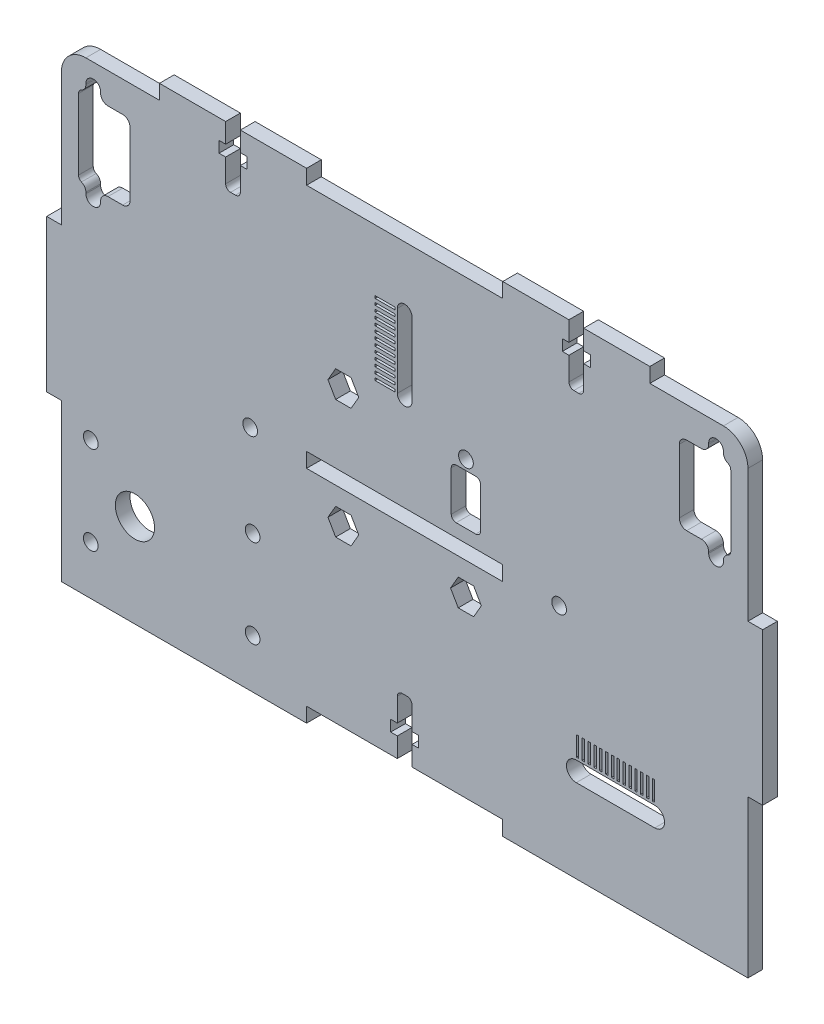
from build123d import *

# Parameters (mm, degrees)
ESBO_O1_W                   = 140
ESBO_O1_H                   = 95
RESSALTO_EXTRUS_O1_DEPTH    = 1.5
ESBO_O2_R                   = 1.5
ESBO_O2_W                   = 40
ESBO_O2_H                   = 3
CORTE_EXTRUS_O1_DEPTH       = 4
ESBO_O3_W                   = 3
ESBO_O3_H                   = 31
ESBO_O3_W_2                 = 30
ESBO_O3_H_2                 = 3
RESSALTO_EXTRUS_O2_DEPTH    = 3
ESBO_O30_R                  = 4
CORTE_EXTRUS_O11_DEPTH      = 1
CORTE_EXTRUS_O11_DEPTH_BACK = 4
ESBO_O31_R                  = 1.5
CORTE_EXTRUS_O12_DEPTH      = 1
CORTE_EXTRUS_O12_DEPTH_BACK = 4
ESBO_O4_W                   = 0.5
ESBO_O4_H                   = 4
CORTE_EXTRUS_O2_DEPTH       = 4
CUT_EXTRUDE2_DEPTH          = 2.5
CUT_EXTRUDE2_DEPTH_BACK     = 2.5
CUT_EXTRUDE6_DEPTH          = 1
CUT_EXTRUDE6_DEPTH_BACK     = 4
CUT_EXTRUDE8_DEPTH          = 2.5
CUT_EXTRUDE8_DEPTH_BACK     = 2.5
SKETCH12_W                  = 4
SKETCH12_H                  = 0.5
CUT_EXTRUDE9_DEPTH          = 4
SKETCH16_R                  = 1.5
CUT_EXTRUDE12_DEPTH         = 2.5
CUT_EXTRUDE12_DEPTH_BACK    = 2.5
FILLET1_R                   = 5


with BuildPart() as part:
    # Esboço1 → Ressalto-extrusão1 (new body, symmetric)
    with BuildSketch(Plane.XY):
        Rectangle(ESBO_O1_W, ESBO_O1_H)
    extrude(amount=RESSALTO_EXTRUS_O1_DEPTH, both=True)

    # Esboço2 → Corte-extrusão1 (cut, through all)
    with BuildSketch(Plane.XY.offset(1.5)):
        with Locations((-31.5, -1)):
            Circle(ESBO_O2_R)
        with Locations((31.5, -1)):
            Circle(ESBO_O2_R)
        with Locations((0, -46)):
            Rectangle(ESBO_O2_W, ESBO_O2_H)
        with Locations((0, -1)):
            Rectangle(ESBO_O2_W, ESBO_O2_H)
    extrude(amount=-CORTE_EXTRUS_O1_DEPTH, mode=Mode.SUBTRACT)

    # Esboço3 → Ressalto-extrusão2 (add, through all)
    with BuildSketch(Plane.XY.offset(1.5)):
        with Locations((71.5, 0)):
            Rectangle(ESBO_O3_W, ESBO_O3_H)
        with Locations((-71.5, 0)):
            Rectangle(ESBO_O3_W, ESBO_O3_H)
        with Locations((-35, 49)):
            Rectangle(ESBO_O3_W_2, ESBO_O3_H_2)
        with Locations((35, 49)):
            Rectangle(ESBO_O3_W_2, ESBO_O3_H_2)
    extrude(amount=-RESSALTO_EXTRUS_O2_DEPTH)

    # Esboço30 → Corte-extrusão11 (cut, two sides)
    with BuildSketch(Plane(origin=(0, 0, -1.5), x_dir=(-1, 0, 0), z_dir=(0, 0, -1))) as corte_extrus_o11_sk:
        with Locations((55, -28.5)):
            Circle(ESBO_O30_R)
    extrude(amount=CORTE_EXTRUS_O11_DEPTH, mode=Mode.SUBTRACT)
    extrude(corte_extrus_o11_sk.sketch, amount=-CORTE_EXTRUS_O11_DEPTH_BACK, mode=Mode.SUBTRACT)

    # Esboço31 → Corte-extrusão12 (cut, two sides)
    with BuildSketch(Plane(origin=(0, 0, -1.5), x_dir=(-1, 0, 0), z_dir=(0, 0, -1))) as corte_extrus_o12_sk:
        with Locations((64, -19.5)):
            Circle(ESBO_O31_R)
        with Locations((64, -37.5)):
            Circle(ESBO_O31_R)
        with Locations((31, -19.5)):
            Circle(ESBO_O31_R)
        with Locations((31, -37.5)):
            Circle(ESBO_O31_R)
    extrude(amount=CORTE_EXTRUS_O12_DEPTH, mode=Mode.SUBTRACT)
    extrude(corte_extrus_o12_sk.sketch, amount=-CORTE_EXTRUS_O12_DEPTH_BACK, mode=Mode.SUBTRACT)

    # Esboço4 → Corte-extrusão2 (cut, through all)
    with BuildSketch(Plane.XY.offset(1.5)):
        with BuildLine():
            Line((35, -26.5), (51, -26.5))
            ThreePointArc((51, -26.5), (53, -28.5), (51, -30.5))
            Line((51, -30.5), (35, -30.5))
            ThreePointArc((35, -30.5), (33, -28.5), (35, -26.5))
        make_face()
        with Locations((35.25, -24)):
            Rectangle(ESBO_O4_W, ESBO_O4_H)
        with Locations((36.442307692, -24)):
            Rectangle(ESBO_O4_W, ESBO_O4_H)
        with Locations((37.634615385, -24)):
            Rectangle(ESBO_O4_W, ESBO_O4_H)
        with Locations((38.826923077, -24)):
            Rectangle(ESBO_O4_W, ESBO_O4_H)
        with Locations((40.019230769, -24)):
            Rectangle(ESBO_O4_W, ESBO_O4_H)
        with Locations((41.211538462, -24)):
            Rectangle(ESBO_O4_W, ESBO_O4_H)
        with Locations((42.403846154, -24)):
            Rectangle(ESBO_O4_W, ESBO_O4_H)
        with Locations((43.596153846, -24)):
            Rectangle(ESBO_O4_W, ESBO_O4_H)
        with Locations((44.788461538, -24)):
            Rectangle(ESBO_O4_W, ESBO_O4_H)
        with Locations((45.980769231, -24)):
            Rectangle(ESBO_O4_W, ESBO_O4_H)
        with Locations((47.173076923, -24)):
            Rectangle(ESBO_O4_W, ESBO_O4_H)
        with Locations((48.365384615, -24)):
            Rectangle(ESBO_O4_W, ESBO_O4_H)
        with Locations((49.557692308, -24)):
            Rectangle(ESBO_O4_W, ESBO_O4_H)
        with Locations((50.75, -24)):
            Rectangle(ESBO_O4_W, ESBO_O4_H)
    extrude(amount=-CORTE_EXTRUS_O2_DEPTH, mode=Mode.SUBTRACT)

    # Sketch5 → Cut-Extrude2 (cut, two sides)
    with BuildSketch(Plane.XY) as cut_extrude2_sk:
        with BuildLine():
            Line((-1.5, -44.5), (1.5, -44.5))
            Line((1.5, -44.5), (1.5, -40.5))
            Line((1.5, -40.5), (2.85, -40.5))
            Line((2.85, -40.5), (2.85, -38.23))
            Line((2.85, -38.23), (1.5, -38.23))
            Line((1.5, -38.23), (1.5, -33.5))
            ThreePointArc((1.5, -33.5), (1.207106781, -32.792893219), (0.5, -32.5))
            Line((0.5, -32.5), (-0.5, -32.5))
            ThreePointArc((-0.5, -32.5), (-1.207106781, -32.792893219), (-1.5, -33.5))
            Line((-1.5, -33.5), (-1.5, -38.23))
            Line((-1.5, -38.23), (-2.85, -38.23))
            Line((-2.85, -38.23), (-2.85, -40.5))
            Line((-2.85, -40.5), (-1.5, -40.5))
            Line((-1.5, -40.5), (-1.5, -44.5))
        make_face()
    extrude(amount=CUT_EXTRUDE2_DEPTH, mode=Mode.SUBTRACT)
    extrude(cut_extrude2_sk.sketch, amount=-CUT_EXTRUDE2_DEPTH_BACK, mode=Mode.SUBTRACT)

    # Sketch8 → Cut-Extrude6 (cut, two sides)
    with BuildSketch(Plane.XY.offset(1.5)) as cut_extrude6_sk:
        with BuildLine():
            Line((-56, 39.75), (-56, 26.75))
            ThreePointArc((-56, 26.75), (-56.439339828, 25.689339828), (-57.5, 25.25))
            Line((-57.5, 25.25), (-60.5, 25.25))
            ThreePointArc((-60.5, 25.25), (-61.560660172, 24.810660172), (-62, 23.75))
            Line((-62, 23.75), (-62, 23.5))
            ThreePointArc((-62, 23.5), (-63.5, 22), (-65, 23.5))
            Line((-65, 23.5), (-65, 23.75))
            ThreePointArc((-65, 23.75), (-65.24500996, 24.571583836), (-65.9, 25.124772708))
            ThreePointArc((-65.9, 25.124772708), (-66.336660027, 25.49356529), (-66.5, 26.041287847))
            Line((-66.5, 26.041287847), (-66.5, 40.458712153))
            ThreePointArc((-66.5, 40.458712153), (-66.336660027, 41.00643471), (-65.9, 41.375227292))
            ThreePointArc((-65.9, 41.375227292), (-65.24500996, 41.928416164), (-65, 42.75))
            Line((-65, 42.75), (-65, 43))
            ThreePointArc((-65, 43), (-63.5, 44.5), (-62, 43))
            Line((-62, 43), (-62, 42.75))
            ThreePointArc((-62, 42.75), (-61.560660172, 41.689339828), (-60.5, 41.25))
            Line((-60.5, 41.25), (-57.5, 41.25))
            ThreePointArc((-57.5, 41.25), (-56.439339828, 40.810660172), (-56, 39.75))
        make_face()
        with BuildLine():
            Line((56, 39.75), (56, 26.75))
            ThreePointArc((56, 26.75), (56.439339828, 25.689339828), (57.5, 25.25))
            Line((57.5, 25.25), (60.5, 25.25))
            ThreePointArc((60.5, 25.25), (61.560660172, 24.810660172), (62, 23.75))
            Line((62, 23.75), (62, 23.5))
            ThreePointArc((62, 23.5), (63.5, 22), (65, 23.5))
            Line((65, 23.5), (65, 23.75))
            ThreePointArc((65, 23.75), (65.24500996, 24.571583836), (65.9, 25.124772708))
            ThreePointArc((65.9, 25.124772708), (66.336660027, 25.49356529), (66.5, 26.041287847))
            Line((66.5, 26.041287847), (66.5, 40.458712153))
            ThreePointArc((66.5, 40.458712153), (66.336660027, 41.00643471), (65.9, 41.375227292))
            ThreePointArc((65.9, 41.375227292), (65.24500996, 41.928416164), (65, 42.75))
            Line((65, 42.75), (65, 43))
            ThreePointArc((65, 43), (63.5, 44.5), (62, 43))
            Line((62, 43), (62, 42.75))
            ThreePointArc((62, 42.75), (61.560660172, 41.689339828), (60.5, 41.25))
            Line((60.5, 41.25), (57.5, 41.25))
            ThreePointArc((57.5, 41.25), (56.439339828, 40.810660172), (56, 39.75))
        make_face()
    extrude(amount=CUT_EXTRUDE6_DEPTH, mode=Mode.SUBTRACT)
    extrude(cut_extrude6_sk.sketch, amount=-CUT_EXTRUDE6_DEPTH_BACK, mode=Mode.SUBTRACT)

    # Sketch11 → Cut-Extrude8 (cut, two sides)
    with BuildSketch(Plane.XY) as cut_extrude8_sk:
        with BuildLine():
            Line((-36.5, 50.5), (-33.5, 50.5))
            Line((-33.5, 50.5), (-33.5, 46.5))
            Line((-33.5, 46.5), (-32.15, 46.5))
            Line((-32.15, 46.5), (-32.15, 44.23))
            Line((-32.15, 44.23), (-33.5, 44.23))
            Line((-33.5, 44.23), (-33.5, 39.5))
            ThreePointArc((-33.5, 39.5), (-33.792893219, 38.792893219), (-34.5, 38.5))
            Line((-34.5, 38.5), (-35.5, 38.5))
            ThreePointArc((-35.5, 38.5), (-36.207106781, 38.792893219), (-36.5, 39.5))
            Line((-36.5, 39.5), (-36.5, 44.23))
            Line((-36.5, 44.23), (-37.85, 44.23))
            Line((-37.85, 44.23), (-37.85, 46.5))
            Line((-37.85, 46.5), (-36.5, 46.5))
            Line((-36.5, 46.5), (-36.5, 50.5))
        make_face()
        with BuildLine():
            Line((33.5, 44.23), (32.15, 44.23))
            Line((32.15, 44.23), (32.15, 46.5))
            Line((32.15, 46.5), (33.5, 46.5))
            Line((33.5, 46.5), (33.5, 50.5))
            Line((33.5, 50.5), (36.5, 50.5))
            Line((36.5, 50.5), (36.5, 46.5))
            Line((36.5, 46.5), (37.85, 46.5))
            Line((37.85, 46.5), (37.85, 44.23))
            Line((37.85, 44.23), (36.5, 44.23))
            Line((36.5, 44.23), (36.5, 39.5))
            ThreePointArc((36.5, 39.5), (36.207106781, 38.792893219), (35.5, 38.5))
            Line((35.5, 38.5), (34.5, 38.5))
            ThreePointArc((34.5, 38.5), (33.792893219, 38.792893219), (33.5, 39.5))
            Line((33.5, 39.5), (33.5, 44.23))
        make_face()
    extrude(amount=CUT_EXTRUDE8_DEPTH, mode=Mode.SUBTRACT)
    extrude(cut_extrude8_sk.sketch, amount=-CUT_EXTRUDE8_DEPTH_BACK, mode=Mode.SUBTRACT)

    # Sketch12 → Cut-Extrude9 (cut, through all)
    with BuildSketch(Plane.XY.offset(1.5)):
        with Locations((-4, 21.458333333)):
            Rectangle(SKETCH12_W, SKETCH12_H)
        with BuildLine():
            Line((-1.5, 20), (-1.5, 35))
            ThreePointArc((-1.5, 35), (0, 36.5), (1.5, 35))
            Line((1.5, 35), (1.5, 20))
            ThreePointArc((1.5, 20), (0, 18.5), (-1.5, 20))
        make_face()
        with Locations((-4, 20.25)):
            Rectangle(SKETCH12_W, SKETCH12_H)
        with Locations((-4, 22.666666667)):
            Rectangle(SKETCH12_W, SKETCH12_H)
        with Locations((-4, 23.875)):
            Rectangle(SKETCH12_W, SKETCH12_H)
        with Locations((-4, 25.083333333)):
            Rectangle(SKETCH12_W, SKETCH12_H)
        with Locations((-4, 26.291666667)):
            Rectangle(SKETCH12_W, SKETCH12_H)
        with Locations((-4, 27.5)):
            Rectangle(SKETCH12_W, SKETCH12_H)
        with Locations((-4, 28.708333333)):
            Rectangle(SKETCH12_W, SKETCH12_H)
        with Locations((-4, 29.916666667)):
            Rectangle(SKETCH12_W, SKETCH12_H)
        with Locations((-4, 31.125)):
            Rectangle(SKETCH12_W, SKETCH12_H)
        with Locations((-4, 32.333333333)):
            Rectangle(SKETCH12_W, SKETCH12_H)
        with Locations((-4, 33.541666667)):
            Rectangle(SKETCH12_W, SKETCH12_H)
        with Locations((-4, 34.75)):
            Rectangle(SKETCH12_W, SKETCH12_H)
    extrude(amount=-CUT_EXTRUDE9_DEPTH, mode=Mode.SUBTRACT)

    # Sketch16 → Cut-Extrude12 (cut, two sides)
    with BuildSketch(Plane.XY) as cut_extrude12_sk:
        with Locations((12.5, 15.35)):
            Circle(SKETCH16_R)
        Polygon((15.64, -8.95), (14.07, -6.230680232), (10.93, -6.230680232), (9.36, -8.95), (10.93, -11.669319768), (14.07, -11.669319768), align=None)
        with BuildLine():
            Line((10.5, 13.35), (14.5, 13.35))
            ThreePointArc((14.5, 13.35), (15.207106781, 13.057106781), (15.5, 12.35))
            Line((15.5, 12.35), (15.5, 4.15))
            ThreePointArc((15.5, 4.15), (15.207106781, 3.442893219), (14.5, 3.15))
            Line((14.5, 3.15), (10.5, 3.15))
            ThreePointArc((10.5, 3.15), (9.792893219, 3.442893219), (9.5, 4.15))
            Line((9.5, 4.15), (9.5, 12.35))
            ThreePointArc((9.5, 12.35), (9.792893219, 13.057106781), (10.5, 13.35))
        make_face()
        Polygon((-9.36, 15.35), (-10.93, 18.069319768), (-14.07, 18.069319768), (-15.64, 15.35), (-14.07, 12.630680232), (-10.93, 12.630680232), align=None)
        Polygon((-9.36, -8.95), (-10.93, -6.230680232), (-14.07, -6.230680232), (-15.64, -8.95), (-14.07, -11.669319768), (-10.93, -11.669319768), align=None)
    extrude(amount=CUT_EXTRUDE12_DEPTH, mode=Mode.SUBTRACT)
    extrude(cut_extrude12_sk.sketch, amount=-CUT_EXTRUDE12_DEPTH_BACK, mode=Mode.SUBTRACT)

    # Fillet1
    fillet1_edges = [part.edges().sort_by_distance(p)[0] for p in [
        (-70, 47.5, 0),
        (70, 47.5, 0),
    ]]
    fillet(fillet1_edges, radius=FILLET1_R)


solid = part.part
